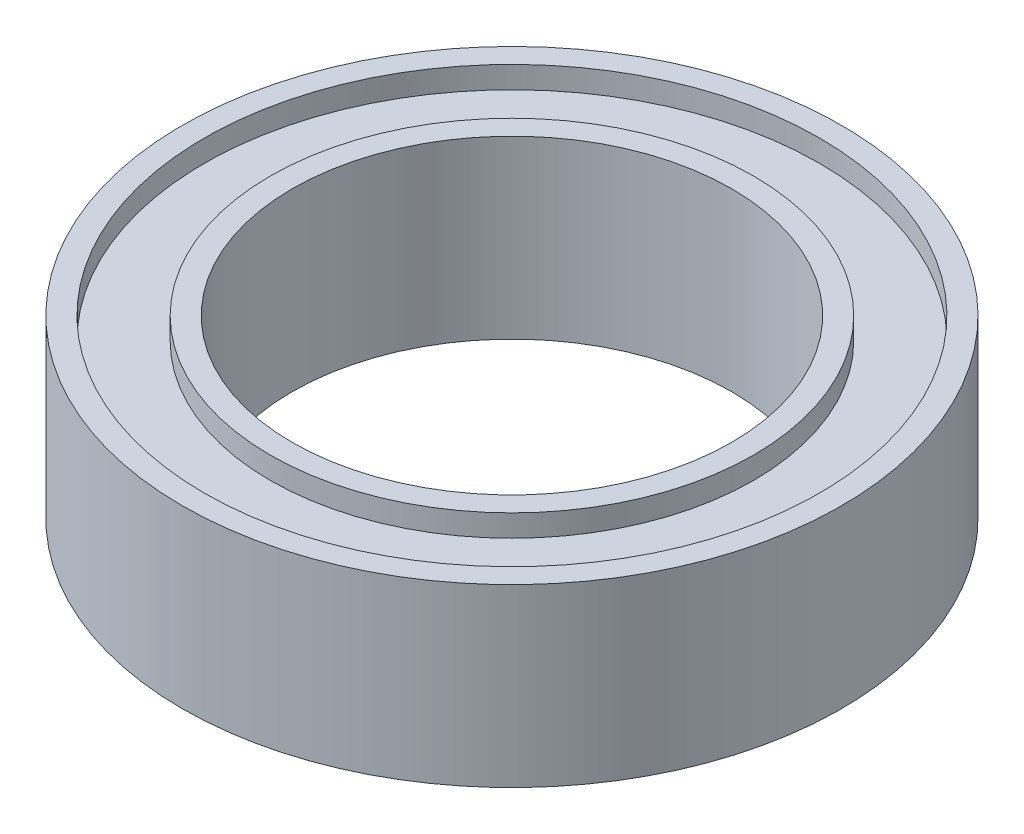
from build123d import *

# Parameters (mm, degrees)
SKETCH1_R           = 7.5
SKETCH1_R_2         = 5
BOSS_EXTRUDE1_DEPTH = 4
SKETCH2_R           = 7
SKETCH2_R_2         = 5.5
CUT_EXTRUDE1_DEPTH  = 0.5


with BuildPart() as part:
    # Sketch1 → Boss-Extrude1 (new body)
    with BuildSketch(Plane(origin=(0, 0, 0), x_dir=(1, 0, 0), z_dir=(0, 1, 0))):
        Circle(SKETCH1_R)
        Circle(SKETCH1_R_2, mode=Mode.SUBTRACT)
    extrude(amount=BOSS_EXTRUDE1_DEPTH)

    # Sketch2 → Cut-Extrude1 (cut)
    with BuildSketch(Plane(origin=(0, 4, 0), x_dir=(1, 0, 0), z_dir=(0, 1, 0))):
        Circle(SKETCH2_R)
        Circle(SKETCH2_R_2, mode=Mode.SUBTRACT)
    cut_extrude1 = extrude(amount=-CUT_EXTRUDE1_DEPTH, mode=Mode.SUBTRACT)

    # Mirror1: Cut-Extrude1 across plane
    add(cut_extrude1.mirror(Plane(origin=(0, 2, 0), x_dir=(0, 0, 1), z_dir=(0, -1, 0))), mode=Mode.SUBTRACT)


solid = part.part
